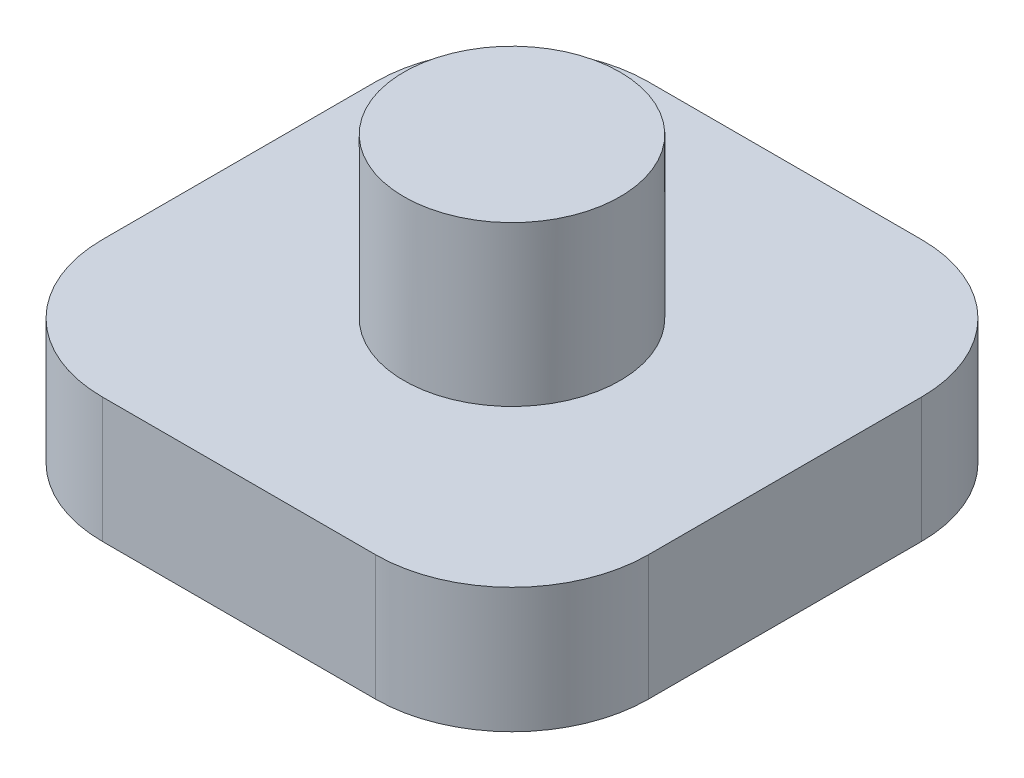
from build123d import *

# Parameters (mm, degrees)
SKETCH1_W           = 12
SKETCH1_H           = 12
BOSS_EXTRUDE1_DEPTH = 2.75
SKETCH3_R           = 2.375
BOSS_EXTRUDE2_DEPTH = 3.5
FILLET1_R           = 3


with BuildPart() as part:
    # Sketch1 → Boss-Extrude1 (new body)
    with BuildSketch(Plane(origin=(0, 0, 0), x_dir=(1, 0, 0), z_dir=(0, 1, 0))):
        with Locations((6, 6)):
            Rectangle(SKETCH1_W, SKETCH1_H)
    extrude(amount=BOSS_EXTRUDE1_DEPTH)

    # Sketch3 → Boss-Extrude2 (add)
    with BuildSketch(Plane(origin=(0, 2.75, 0), x_dir=(1, 0, 0), z_dir=(0, 1, 0))):
        with Locations((6, 6)):
            Circle(SKETCH3_R)
    extrude(amount=BOSS_EXTRUDE2_DEPTH)

    # Fillet1
    fillet1_edges = [part.edges().sort_by_distance(p)[0] for p in [
        (0, 1.375, -12),
        (12, 1.375, -12),
        (12, 1.375, 0),
        (0, 1.375, 0),
    ]]
    fillet(fillet1_edges, radius=FILLET1_R)


solid = part.part
